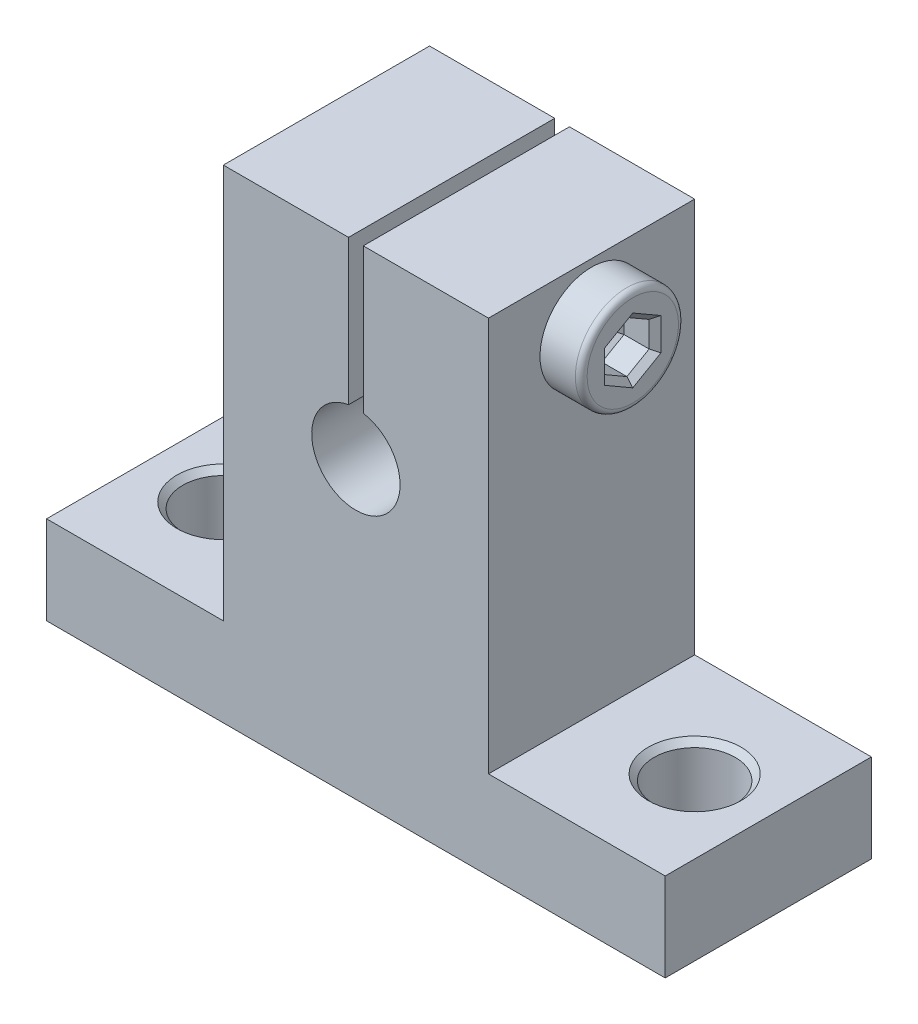
from build123d import *

# Parameters (mm, degrees)
SKETCH1_R                = 3
BOSS_EXTRUDE1_DEPTH      = 14
SKETCH3_W                = 1
SKETCH3_H                = 11.790173319
CUT_EXTRUDE1_DEPTH       = 19
SKETCH2_R                = 2
CUT_EXTRUDE3_DEPTH       = 31
SKETCH5_R                = 2.75
CUT_EXTRUDE5_DEPTH       = 22
TAGLIO_ESTRUSIONE1_DEPTH = 2.5
SMUSSO1_SIZE             = 0.4
RACCORDO1_R              = 0.4
SMUSSO2_SIZE             = 0.4


with BuildPart() as part:
    # Sketch1 → Boss-Extrude1 (new body)
    with BuildSketch(Plane.XY):
        Polygon((-21, 0), (21, 0), (21, 6), (9, 6), (9, 32.8), (-9, 32.8), (-9, 6), (-21, 6), align=None)
        with Locations((0, 20)):
            Circle(SKETCH1_R, mode=Mode.SUBTRACT)
    extrude(amount=BOSS_EXTRUDE1_DEPTH)

    # Sketch3 → Cut-Extrude1 (cut)
    with BuildSketch(Plane.XY.offset(14)):
        with Locations((0, 26.904913341)):
            Rectangle(SKETCH3_W, SKETCH3_H)
    extrude(amount=-CUT_EXTRUDE1_DEPTH, mode=Mode.SUBTRACT)

    # Sketch2 → Cut-Extrude3 (cut)
    with BuildSketch(Plane(origin=(9, 0, 0), x_dir=(0, 0, -1), z_dir=(1, 0, 0))):
        with Locations((-7, 28.8)):
            Circle(SKETCH2_R)
    extrude(amount=-CUT_EXTRUDE3_DEPTH, mode=Mode.SUBTRACT)

    # Sketch5 → Cut-Extrude5 (cut)
    with BuildSketch(Plane(origin=(0, 6, 0), x_dir=(1, 0, 0), z_dir=(0, 1, 0))):
        with Locations((16, -7)):
            Circle(SKETCH5_R)
        with Locations((-16, -7)):
            Circle(SKETCH5_R)
    extrude(amount=-CUT_EXTRUDE5_DEPTH, mode=Mode.SUBTRACT)

    # Smusso2
    smusso2_edges = [part.edges().sort_by_distance(p)[0] for p in [
        (13.25, 6, 7),
        (-18.75, 6, 7),
    ]]
    chamfer(smusso2_edges, length=SMUSSO2_SIZE)


with BuildPart() as body_2:
    # Schizzo1 → Rivoluzione1 (revolve)
    with BuildSketch(Plane.XY.offset(7)):
        Polygon((11.8, 28.8), (-11, 28.8), (-11, 30.4), (-10.6, 30.8), (9, 30.8), (9, 32.3), (11.8, 32.3), align=None)
    revolve(axis=Axis((-22.704724307, 28.8, 7), (1, 0, 0)))

    # Schizzo2 → Taglio-Estrusione1 (cut)
    with BuildSketch(Plane(origin=(11.8, 0, 0), x_dir=(0, 0, -1), z_dir=(1, 0, 0))):
        Polygon((-7, 30.538280632), (-8.505395186, 29.669140316), (-8.505395186, 27.930859684), (-7, 27.061719368), (-5.494604814, 27.930859684), (-5.494604814, 29.669140316), align=None)
    extrude(amount=-TAGLIO_ESTRUSIONE1_DEPTH, mode=Mode.SUBTRACT)

    # Smusso1
    smusso1_edges = [body_2.edges().sort_by_distance(p)[0] for p in [
        (9.3, 30.103710474, 6.247302407),
        (9.3, 28.8, 5.494604814),
        (9.3, 27.496289526, 6.247302407),
        (9.3, 27.496289526, 7.752697593),
        (9.3, 28.8, 8.505395186),
        (9.3, 30.103710474, 7.752697593),
        (11.8, 30.103710474, 6.247302407),
        (11.8, 30.103710474, 7.752697593),
        (11.8, 28.8, 8.505395186),
        (11.8, 27.496289526, 7.752697593),
        (11.8, 27.496289526, 6.247302407),
        (11.8, 28.8, 5.494604814),
    ]]
    chamfer(smusso1_edges, length=SMUSSO1_SIZE)

    # Raccordo1
    raccordo1_edges = [body_2.edges().sort_by_distance(p)[0] for p in [
        (11.8, 25.3, 7),
    ]]
    fillet(raccordo1_edges, radius=RACCORDO1_R)


solid = Compound([part.part, body_2.part])
